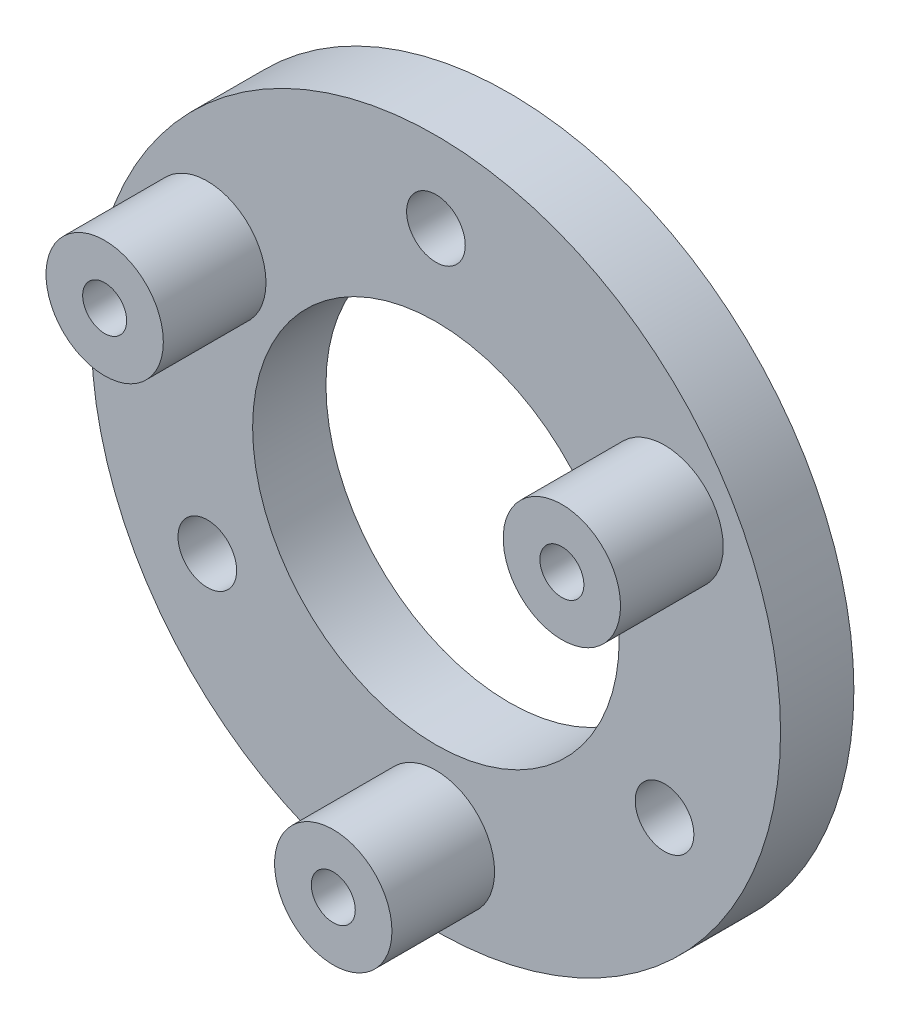
from build123d import *

# Parameters (mm, degrees)
SKETCH1_R               = 23.5
SKETCH1_R_2             = 12.5
BOSS_EXTRUDE1_DEPTH     = 5
SKETCH2_R               = 2
CUT_EXTRUDE1_DEPTH      = 3
SKETCH3_R               = 1.5
CUT_EXTRUDE2_DEPTH      = 90
CUT_EXTRUDE2_DEPTH_BACK = 54
SKETCH6_R               = 4
SKETCH6_R_2             = 1.5
BOSS_EXTRUDE3_DEPTH     = 7
SKETCH7_R               = 4
SKETCH7_R_2             = 1.5
BOSS_EXTRUDE4_DEPTH     = 3


with BuildPart() as part:
    # Sketch1 → Boss-Extrude1 (new body)
    with BuildSketch(Plane.XY):
        Circle(SKETCH1_R)
        Circle(SKETCH1_R_2, mode=Mode.SUBTRACT)
    extrude(amount=BOSS_EXTRUDE1_DEPTH)

    # Sketch2 → Cut-Extrude1 (cut)
    with BuildSketch(Plane.XY.offset(5)):
        with Locations((0, 18)):
            Circle(SKETCH2_R)
        with Locations((15.588457268, -9)):
            Circle(SKETCH2_R)
        with Locations((-15.588457268, -9)):
            Circle(SKETCH2_R)
    extrude(amount=-CUT_EXTRUDE1_DEPTH, mode=Mode.SUBTRACT)

    # Sketch3 → Cut-Extrude2 (cut, two sides)
    with BuildSketch(Plane.XY.offset(5)) as cut_extrude2_sk:
        with Locations((-15.588457268, 9)):
            Circle(SKETCH3_R)
        with Locations((15.588457268, 9)):
            Circle(SKETCH3_R)
        with Locations((0, -18)):
            Circle(SKETCH3_R)
    extrude(amount=CUT_EXTRUDE2_DEPTH, mode=Mode.SUBTRACT)
    extrude(cut_extrude2_sk.sketch, amount=-CUT_EXTRUDE2_DEPTH_BACK, mode=Mode.SUBTRACT)

    # Sketch6 → Boss-Extrude3 (add)
    with BuildSketch(Plane.XY.offset(5)):
        with Locations((-15.588457268, 9)):
            Circle(SKETCH6_R)
        with Locations((-15.588457268, 9)):
            Circle(SKETCH6_R_2, mode=Mode.SUBTRACT)
        with Locations((15.588457268, 9)):
            Circle(SKETCH6_R)
        with Locations((15.588457268, 9)):
            Circle(SKETCH6_R_2, mode=Mode.SUBTRACT)
        with Locations((0, -18)):
            Circle(SKETCH6_R)
        with Locations((0, -18)):
            Circle(SKETCH6_R_2, mode=Mode.SUBTRACT)
    extrude(amount=BOSS_EXTRUDE3_DEPTH)

    # Sketch7 → Boss-Extrude4 (add)
    with BuildSketch(Plane.XY.offset(12)):
        with Locations((-15.588457268, 9)):
            Circle(SKETCH7_R)
        with Locations((-15.588457268, 9)):
            Circle(SKETCH7_R_2, mode=Mode.SUBTRACT)
        with Locations((15.588457268, 9)):
            Circle(SKETCH7_R)
        with Locations((15.588457268, 9)):
            Circle(SKETCH7_R_2, mode=Mode.SUBTRACT)
        with Locations((0, -18)):
            Circle(SKETCH7_R)
        with Locations((0, -18)):
            Circle(SKETCH7_R_2, mode=Mode.SUBTRACT)
    extrude(amount=-BOSS_EXTRUDE4_DEPTH)


solid = part.part
